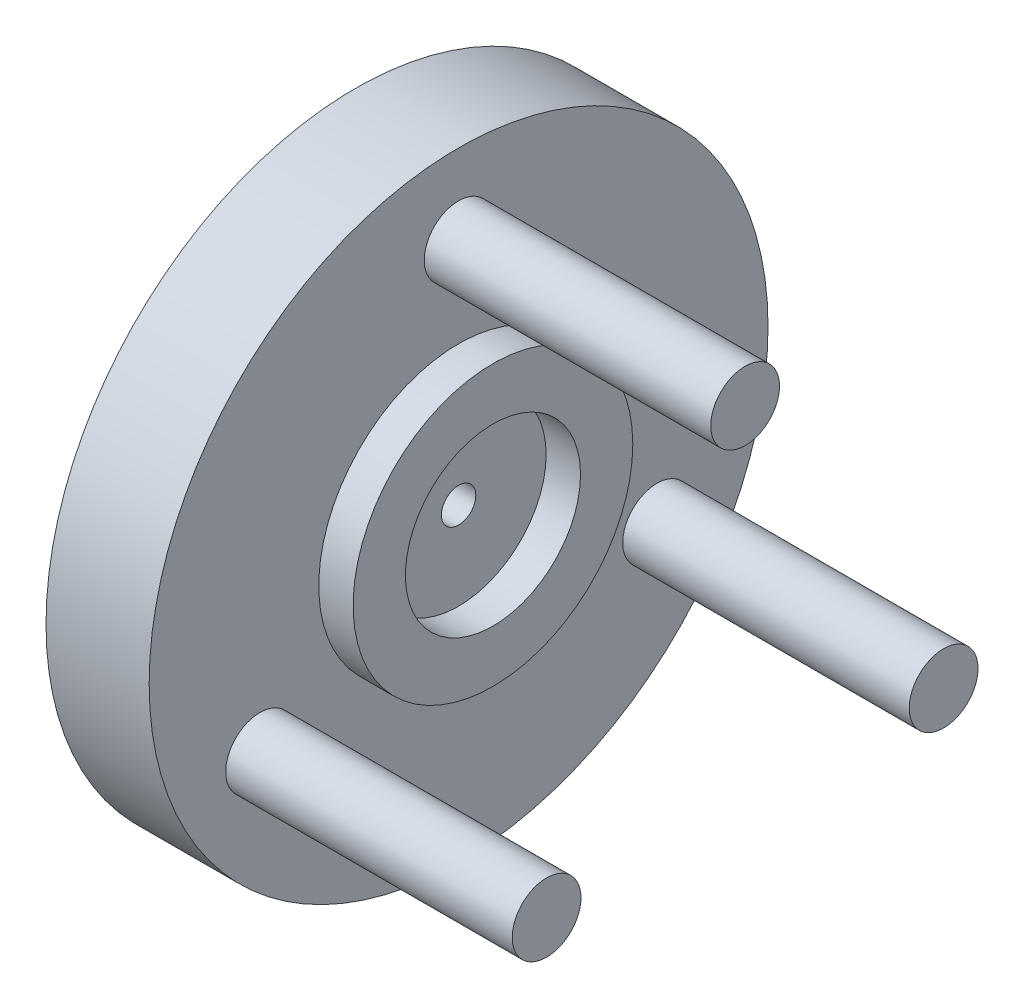
from build123d import *

# Parameters (mm, degrees)
SKETCH1_R           = 27
SKETCH1_R_2         = 2.8
BOSS_EXTRUDE2_DEPTH = 4
SKETCH2_R           = 27
SKETCH2_R_2         = 2.8
SKETCH2_R_3         = 1.5
BOSS_EXTRUDE3_DEPTH = 5
SKETCH3_R           = 3
BOSS_EXTRUDE4_DEPTH = 25
SKETCH4_R           = 12.2
SKETCH4_R_2         = 7.64
BOSS_EXTRUDE5_DEPTH = 3


with BuildPart() as part:
    # Sketch1 → Boss-Extrude2 (new body)
    with BuildSketch(Plane(origin=(0, 0, 0), x_dir=(0, 0, -1), z_dir=(1, 0, 0))):
        Circle(SKETCH1_R)
        Circle(SKETCH1_R_2, mode=Mode.SUBTRACT)
    extrude(amount=BOSS_EXTRUDE2_DEPTH)

    # Sketch2 → Boss-Extrude3 (add)
    with BuildSketch(Plane(origin=(4, 0, 0), x_dir=(0, 0, -1), z_dir=(1, 0, 0))):
        Circle(SKETCH2_R)
        Circle(SKETCH2_R_2, mode=Mode.SUBTRACT)
        Circle(SKETCH2_R_2)
        Circle(SKETCH2_R_3, mode=Mode.SUBTRACT)
    extrude(amount=BOSS_EXTRUDE3_DEPTH)

    # Sketch3 → Boss-Extrude4 (add)
    with BuildSketch(Plane(origin=(9, 0, 0), x_dir=(0, 0, -1), z_dir=(1, 0, 0))):
        with Locations((0, 20)):
            Circle(SKETCH3_R)
        with Locations((17.320508076, -10)):
            Circle(SKETCH3_R)
        with Locations((-17.320508076, -10)):
            Circle(SKETCH3_R)
    extrude(amount=BOSS_EXTRUDE4_DEPTH)

    # Sketch4 → Boss-Extrude5 (add)
    with BuildSketch(Plane(origin=(9, 0, 0), x_dir=(0, 0, -1), z_dir=(1, 0, 0))):
        Circle(SKETCH4_R)
        Circle(SKETCH4_R_2, mode=Mode.SUBTRACT)
    extrude(amount=BOSS_EXTRUDE5_DEPTH)


solid = part.part
